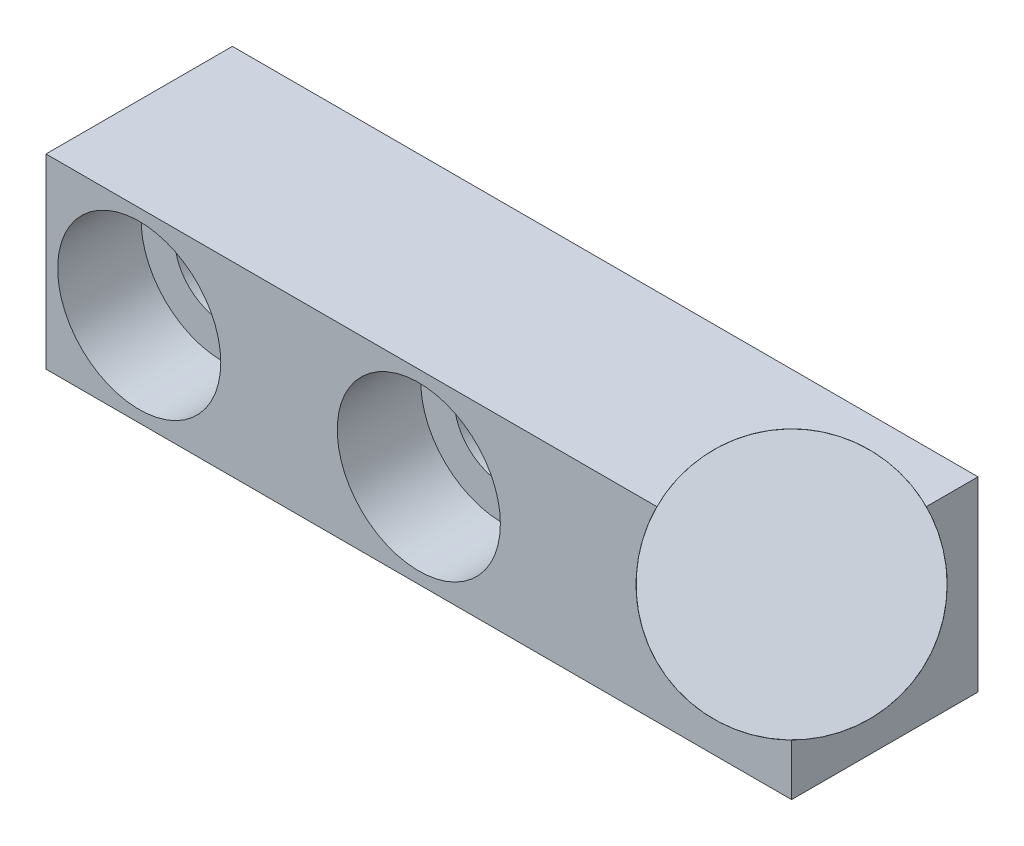
from build123d import *

# Parameters (mm, degrees)
SKETCH1_W                                      = 25.4
SKETCH1_H                                      = 6.35
BOSS_EXTRUDE1_DEPTH                            = 6.35
CBORE_FOR_4_SOCKET_HEAD_CAP_SCREW1_D           = 3.2639
CBORE_FOR_4_SOCKET_HEAD_CAP_SCREW1_DEPTH       = 7.5946
CBORE_FOR_4_SOCKET_HEAD_CAP_SCREW1_CBORE_D     = 5.55752
CBORE_FOR_4_SOCKET_HEAD_CAP_SCREW1_CBORE_DEPTH = 2.8448
CBORE_FOR_4_SOCKET_HEAD_CAP_SCREW1_TIP         = 0.980574487
SKETCH4_R                                      = 3.7465
BOSS_EXTRUDE2_DEPTH                            = 5.715


with BuildPart() as part:
    # Sketch1 → Boss-Extrude1 (new body)
    with BuildSketch(Plane.XY):
        Rectangle(SKETCH1_W, SKETCH1_H)
    extrude(amount=BOSS_EXTRUDE1_DEPTH)

    # CBORE for _4 Socket Head Cap Screw1
    with Locations(Plane.XY.offset(6.35)):
        with Locations((-9.525, 0), (0, 0)):
            CounterBoreHole(CBORE_FOR_4_SOCKET_HEAD_CAP_SCREW1_D / 2, CBORE_FOR_4_SOCKET_HEAD_CAP_SCREW1_CBORE_D / 2, CBORE_FOR_4_SOCKET_HEAD_CAP_SCREW1_CBORE_DEPTH, depth=CBORE_FOR_4_SOCKET_HEAD_CAP_SCREW1_DEPTH)
            with Locations((0, 0, -(CBORE_FOR_4_SOCKET_HEAD_CAP_SCREW1_DEPTH + CBORE_FOR_4_SOCKET_HEAD_CAP_SCREW1_TIP / 2))):  # 118° drill point
                Cone(0, CBORE_FOR_4_SOCKET_HEAD_CAP_SCREW1_D / 2, CBORE_FOR_4_SOCKET_HEAD_CAP_SCREW1_TIP, mode=Mode.SUBTRACT)

    # Sketch4 → Boss-Extrude2 (add)
    with BuildSketch(Plane(origin=(12.7, 3.175, 6.35), x_dir=(0.4082482904638631, 0.408248290463863, -0.8164965809277261), z_dir=(0.5773502691896258, 0.5773502691896257, 0.5773502691896257))):
        Circle(SKETCH4_R)
    extrude(amount=-BOSS_EXTRUDE2_DEPTH)


solid = part.part
